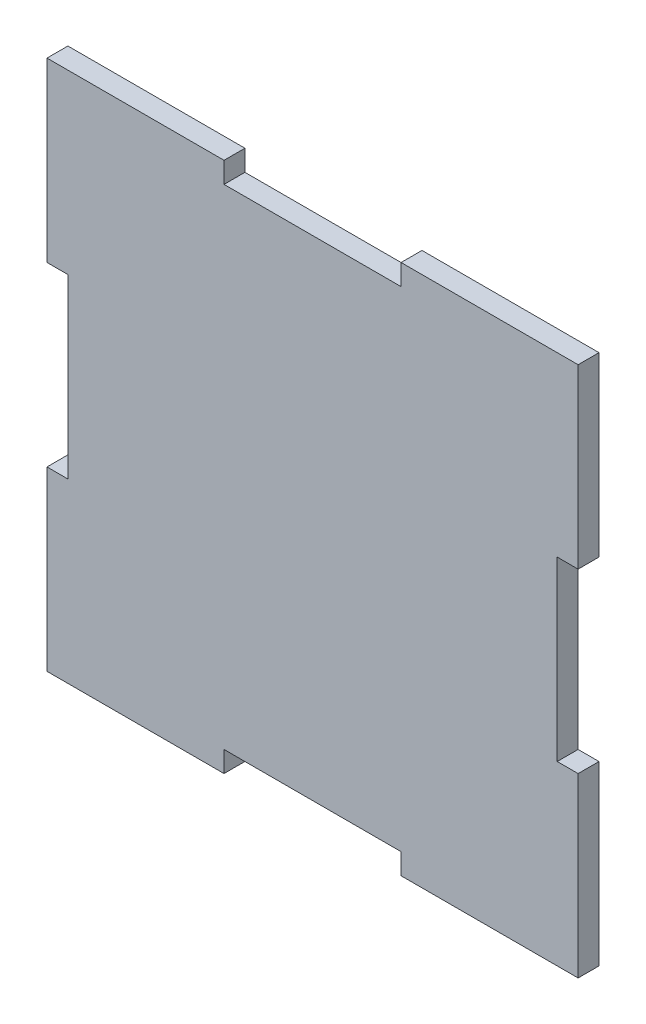
from build123d import *

# Parameters (mm, degrees)
PLATE_DEPTH = 2.9972


with BuildPart() as part:
    # bottom outline → plate (new body)
    with BuildSketch(Plane.XY):
        Polygon((0, 50.8), (0, 76.2), (25.4, 76.2), (25.4, 73.2028), (50.8, 73.2028), (50.8, 76.2), (76.2, 76.2), (76.2, 50.8), (73.2028, 50.8), (73.2028, 25.4), (76.2, 25.4), (76.2, 0), (50.8, 0), (50.8, 2.9972), (25.4, 2.9972), (25.4, 0), (0, 0), (0, 25.4), (2.9972, 25.4), (2.9972, 50.8), align=None)
    extrude(amount=PLATE_DEPTH)


solid = part.part
